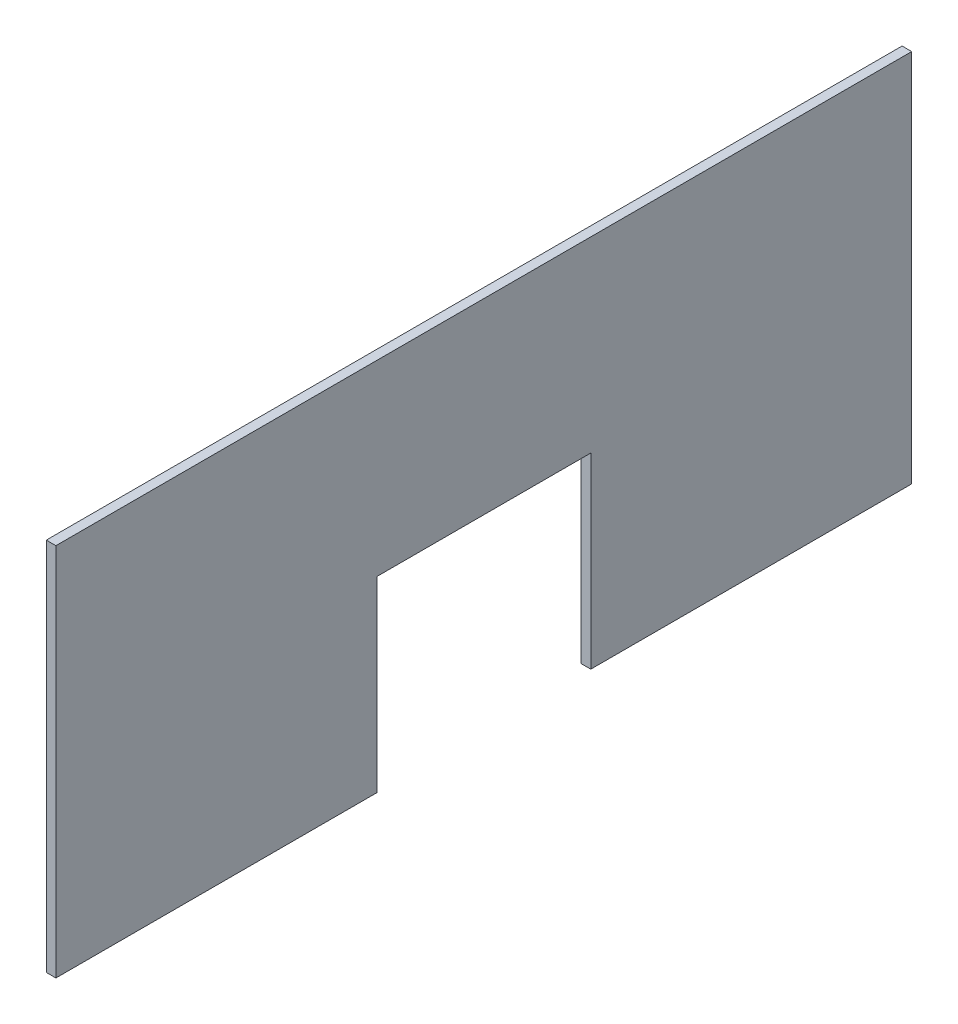
from build123d import *

# Parameters (mm, degrees)
EXTRUDE_1_DEPTH = 18


with BuildPart() as part:
    # Эскиз1 → Бобышка-Вытянуть1 (new body)
    with BuildSketch(Plane(origin=(0, 0, 0), x_dir=(0, 0, -1), z_dir=(1, 0, 0))):
        Polygon((32.681788792, 1580.395145924), (32.681788792, 880.395145924), (632.681788792, 880.395145924), (632.681788792, 1230.395145924), (1032.681788792, 1230.395145924), (1032.681788792, 880.395145924), (1632.681788792, 880.395145924), (1632.681788792, 1580.395145924), align=None)
    extrude(amount=EXTRUDE_1_DEPTH)


solid = part.part
